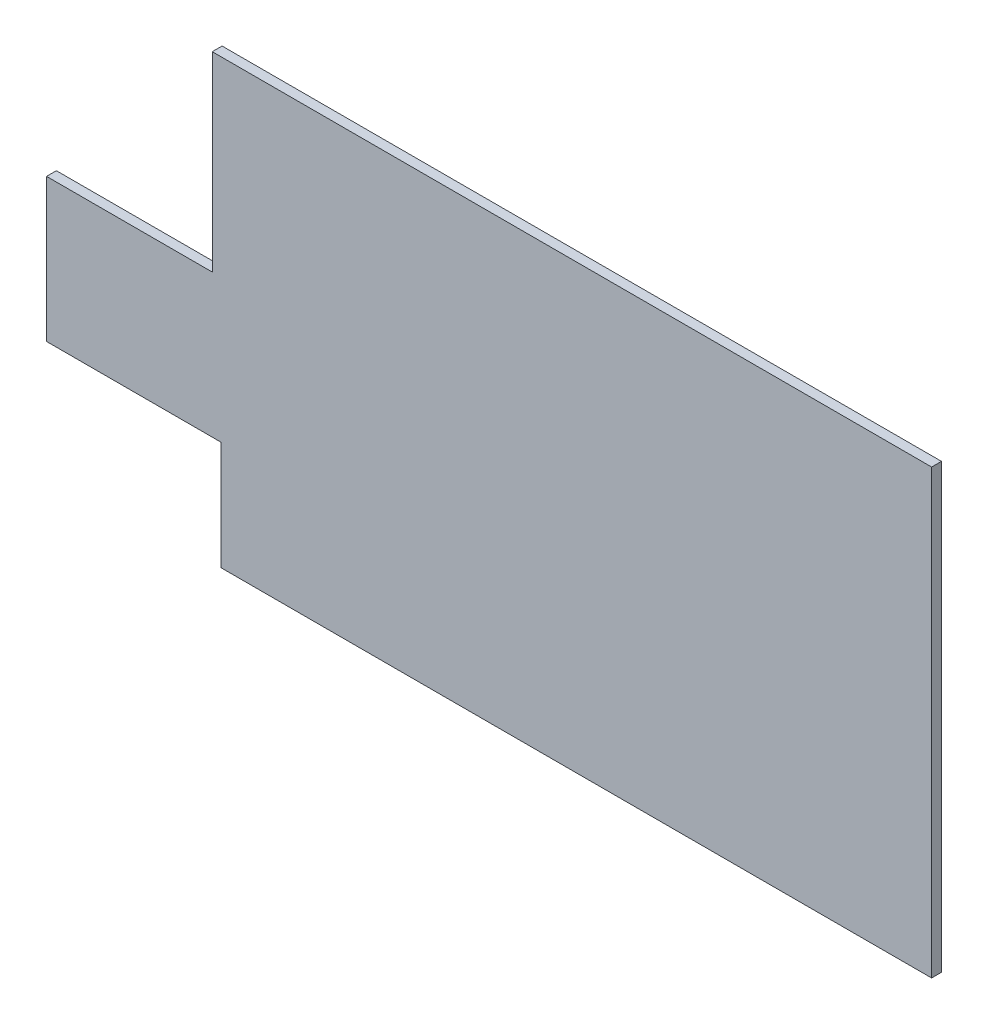
from build123d import *

# Parameters (mm, degrees)
SKETCH_1_W          = 180
SKETCH_1_H          = 90
EXTRUDE_1_DEPTH     = 2
SKETCH_2_W          = 38.532921991
SKETCH_2_H          = 39.172829466
SKETCH_2_W_2        = 36.71863442
SKETCH_2_H_2        = 23.941536141
CUT_EXTRUDE_1_DEPTH = 10


with BuildPart() as part:
    # 草图1 → 凸台-拉伸1 (new body)
    with BuildSketch(Plane.XY):
        Rectangle(SKETCH_1_W, SKETCH_1_H)
    extrude(amount=EXTRUDE_1_DEPTH)

    # 草图2 → 切除-拉伸1 (cut)
    with BuildSketch(Plane(origin=(0, 0, 0), x_dir=(-1, 0, 0), z_dir=(0, 0, -1))):
        with Locations((75.566653183, 25.775254146)):
            Rectangle(SKETCH_2_W, SKETCH_2_H)
        with Locations((72.875299328, -34.863350459)):
            Rectangle(SKETCH_2_W_2, SKETCH_2_H_2)
    extrude(amount=-CUT_EXTRUDE_1_DEPTH, mode=Mode.SUBTRACT)


solid = part.part
